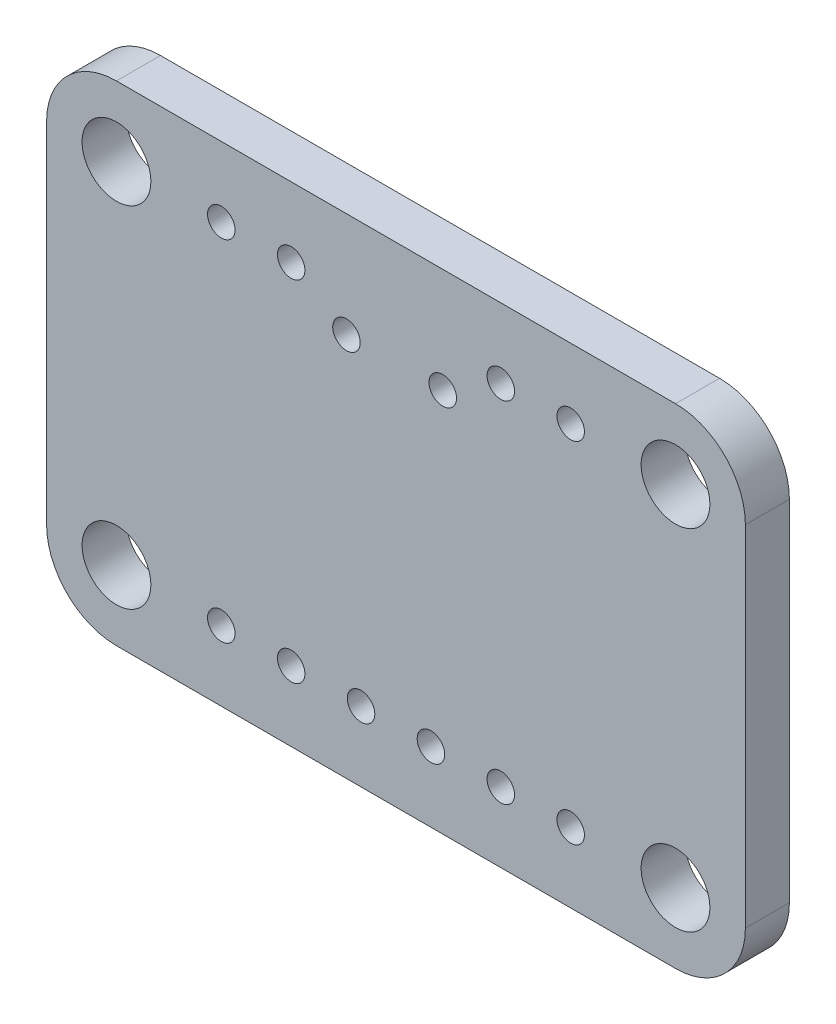
from build123d import *

# Parameters (mm, degrees)
MODEL_R             = 0.5
MODEL_R_2           = 1.25
BOSS_EXTRUDE1_DEPTH = 1.6


with BuildPart() as part:
    # Model → Boss-Extrude1 (new body)
    with BuildSketch(Plane.XY):
        with BuildLine():
            Line((0, 15.24), (0, 2.54))
            ThreePointArc((0, 2.54), (0.743948776, 0.743948776), (2.54, 0))
            Line((2.54, 0), (22.86, 0))
            ThreePointArc((22.86, 0), (24.656051224, 0.743948776), (25.4, 2.54))
            Line((25.4, 2.54), (25.4, 15.24))
            ThreePointArc((25.4, 15.24), (24.656051224, 17.036051224), (22.86, 17.78))
            Line((22.86, 17.78), (2.54, 17.78))
            ThreePointArc((2.54, 17.78), (0.743948776, 17.036051224), (0, 15.24))
        make_face()
        with Locations((6.35, 2.54)):
            Circle(MODEL_R, mode=Mode.SUBTRACT)
        with Locations((8.89, 2.54)):
            Circle(MODEL_R, mode=Mode.SUBTRACT)
        with Locations((11.43, 2.54)):
            Circle(MODEL_R, mode=Mode.SUBTRACT)
        with Locations((13.97, 2.54)):
            Circle(MODEL_R, mode=Mode.SUBTRACT)
        with Locations((16.51, 2.54)):
            Circle(MODEL_R, mode=Mode.SUBTRACT)
        with Locations((19.05, 2.54)):
            Circle(MODEL_R, mode=Mode.SUBTRACT)
        with Locations((16.51, 15.24)):
            Circle(MODEL_R, mode=Mode.SUBTRACT)
        with Locations((19.05, 15.24)):
            Circle(MODEL_R, mode=Mode.SUBTRACT)
        with Locations((6.35, 15.24)):
            Circle(MODEL_R, mode=Mode.SUBTRACT)
        with Locations((8.89, 15.24)):
            Circle(MODEL_R, mode=Mode.SUBTRACT)
        with Locations((2.54, 15.24)):
            Circle(MODEL_R_2, mode=Mode.SUBTRACT)
        with Locations((22.86, 15.24)):
            Circle(MODEL_R_2, mode=Mode.SUBTRACT)
        with Locations((2.54, 2.54)):
            Circle(MODEL_R_2, mode=Mode.SUBTRACT)
        with Locations((22.86, 2.54)):
            Circle(MODEL_R_2, mode=Mode.SUBTRACT)
        with Locations((10.9, 13.97)):
            Circle(MODEL_R, mode=Mode.SUBTRACT)
        with Locations((14.4, 13.97)):
            Circle(MODEL_R, mode=Mode.SUBTRACT)
    extrude(amount=-BOSS_EXTRUDE1_DEPTH)


solid = part.part
